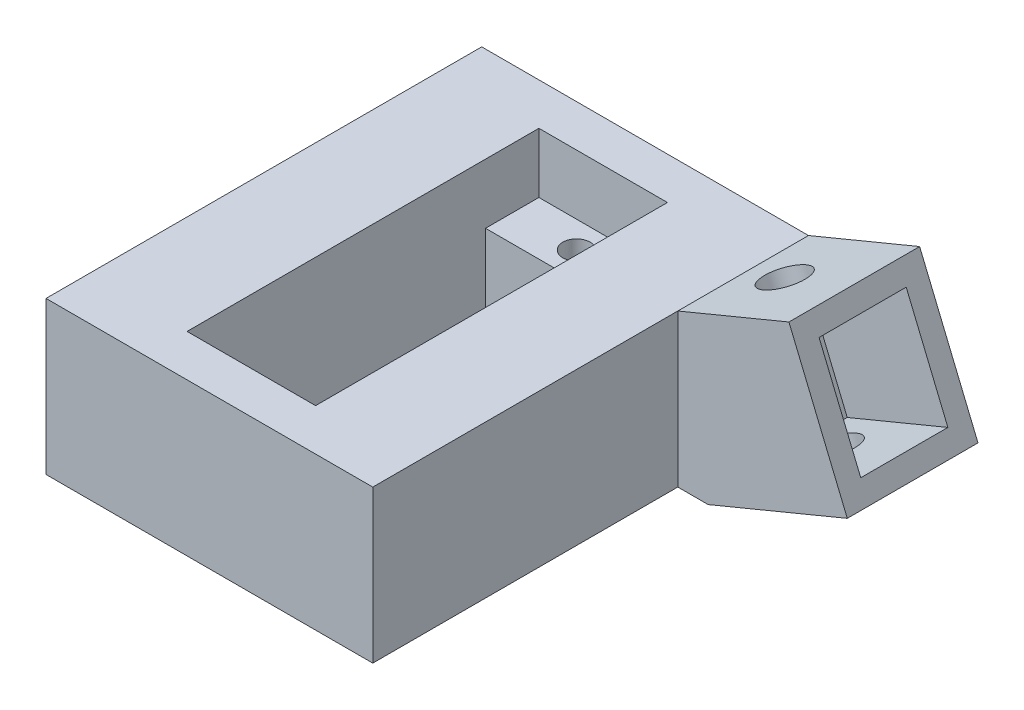
from build123d import *

# Parameters (mm, degrees)
BOSS_EXTRUDE1_DEPTH = 40
SKETCH4_W           = 11.8
SKETCH4_H           = 32.3
CUT_EXTRUDE1_DEPTH  = 5.5
SKETCH5_W           = 11.8
SKETCH5_H           = 22.5
CUT_EXTRUDE2_DEPTH  = 9.498848241
SKETCH6_R           = 1.25
CUT_EXTRUDE3_DEPTH  = 9.498848241
BOSS_EXTRUDE2_DEPTH = 12
SKETCH8_W           = 8
SKETCH8_H           = 10
CUT_EXTRUDE4_DEPTH  = 10
SKETCH9_R           = 2
CUT_EXTRUDE5_DEPTH  = 30.384991323


with BuildPart() as part:
    # Sketch1 → Boss-Extrude1 (new body)
    with BuildSketch(Plane.XY):
        Polygon((8.670952565, 9.003587153), (-11.329047435, 9.003587153), (-21.329047435, 9.003587153), (-21.329047435, -4.995261088), (-11.329047435, -4.995261088), (8.670952565, -4.995261088), align=None)
    extrude(amount=BOSS_EXTRUDE1_DEPTH)

    # Sketch4 → Cut-Extrude1 (cut)
    with BuildSketch(Plane(origin=(0, 9.003587153, 0), x_dir=(1, 0, 0), z_dir=(0, 1, 0))):
        with Locations((-6.329047435, -20)):
            Rectangle(SKETCH4_W, SKETCH4_H)
    extrude(amount=-CUT_EXTRUDE1_DEPTH, mode=Mode.SUBTRACT)

    # Sketch5 → Cut-Extrude2 (cut, through all)
    with BuildSketch(Plane(origin=(0, 3.503587153, 0), x_dir=(1, 0, 0), z_dir=(0, 1, 0))):
        with Locations((-6.329047435, -20)):
            Rectangle(SKETCH5_W, SKETCH5_H)
    extrude(amount=-CUT_EXTRUDE2_DEPTH, mode=Mode.SUBTRACT)

    # Sketch6 → Cut-Extrude3 (cut, through all)
    with BuildSketch(Plane(origin=(0, 3.503587153, 0), x_dir=(1, 0, 0), z_dir=(0, 1, 0))):
        with Locations((-6.329047435, -6.3)):
            Circle(SKETCH6_R)
        with Locations((-6.329047435, -33.7)):
            Circle(SKETCH6_R)
    extrude(amount=-CUT_EXTRUDE3_DEPTH, mode=Mode.SUBTRACT)

    # Sketch7 → Boss-Extrude2 (add)
    with BuildSketch(Plane.XY):
        Polygon((8.670952565, 9.003587153), (8.670952565, -4.995261088), (11.458506302, -4.995261088), (24.231440373, 0.295461436), (20.787289482, 8.610377228), (18.87387232, 13.229774891), align=None)
    extrude(amount=BOSS_EXTRUDE2_DEPTH)

    # Sketch8 → Cut-Extrude4 (cut)
    with BuildSketch(Plane(origin=(20.787289482, 8.610377228, 0), x_dir=(0, 0, -1), z_dir=(0.923879533, 0.382683432, 0))):
        with Locations((-6, -2)):
            Rectangle(SKETCH8_W, SKETCH8_H)
    extrude(amount=-CUT_EXTRUDE4_DEPTH, mode=Mode.SUBTRACT)

    # Sketch9 → Cut-Extrude5 (cut, through all)
    with BuildSketch(Plane(origin=(3.444150891, -8.314915793, 0), x_dir=(0.923879533, 0.382683432, 0), z_dir=(0.382683432, -0.923879533, 0))):
        with Locations((15.587337893, 6)):
            Circle(SKETCH9_R)
    extrude(amount=-CUT_EXTRUDE5_DEPTH, mode=Mode.SUBTRACT)


solid = part.part
